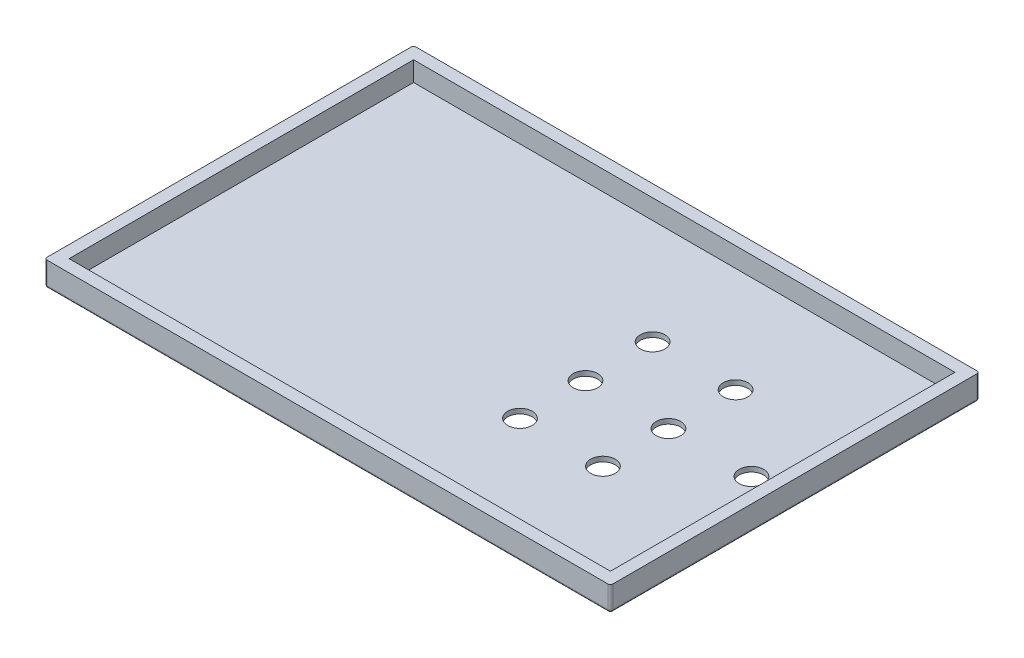
from build123d import *

# Parameters (mm, degrees)
SKETCH1_W           = 230
SKETCH1_H           = 150
BOSS_EXTRUDE3_DEPTH = 10
SKETCH3_W           = 220.032470936
SKETCH3_H           = 140.023771478
CUT_EXTRUDE1_DEPTH  = 8
FILLET1_R           = 1
FILLET2_R           = 1
FILLET3_R           = 1
SKETCH6_R           = 5
CUT_EXTRUDE3_DEPTH  = 10


with BuildPart() as part:
    # Sketch1 → Boss-Extrude3 (new body)
    with BuildSketch(Plane(origin=(0, 0, 0), x_dir=(1, 0, 0), z_dir=(0, 1, 0))):
        with Locations((115, 75)):
            Rectangle(SKETCH1_W, SKETCH1_H)
    extrude(amount=BOSS_EXTRUDE3_DEPTH)

    # Sketch3 → Cut-Extrude1 (cut)
    with BuildSketch(Plane(origin=(0, 10, 0), x_dir=(1, 0, 0), z_dir=(0, 1, 0))):
        with Locations((115, 75)):
            Rectangle(SKETCH3_W, SKETCH3_H)
    extrude(amount=-CUT_EXTRUDE1_DEPTH, mode=Mode.SUBTRACT)

    # Fillet1
    fillet1_edges = [part.edges().sort_by_distance(p)[0] for p in [
        (0, 5, 0),
    ]]
    fillet(fillet1_edges, radius=FILLET1_R)

    # Fillet2
    fillet2_edges = [part.edges().sort_by_distance(p)[0] for p in [
        (0, 5, -150),
        (230, 5, -150),
        (230, 5, 0),
    ]]
    fillet(fillet2_edges, radius=FILLET2_R)

    # Fillet3
    fillet3_edges = [part.edges().sort_by_distance(p)[0] for p in [
        (115, 0, 0),
        (0.292893219, 0, -0.292893219),
        (0, 0, -75),
        (115, 0, -150),
        (230, 0, -75),
        (229.707106781, 0, -149.707106781),
        (229.707106781, 0, -0.292893219),
        (0.292893219, 0, -149.707106781),
    ]]
    fillet(fillet3_edges, radius=FILLET3_R)

    # Sketch6 → Cut-Extrude3 (cut)
    with BuildSketch(Plane.XZ):
        with Locations((144.826508181, -48.408466726)):
            Circle(SKETCH6_R)
        with Locations((178.556568371, -48.408466726)):
            Circle(SKETCH6_R)
        with Locations((178.592552161, -75)):
            Circle(SKETCH6_R)
        with Locations((144.862491971, -75)):
            Circle(SKETCH6_R)
        with Locations((144.862491971, -102.290057641)):
            Circle(SKETCH6_R)
        with Locations((178.592552161, -102.290057641)):
            Circle(SKETCH6_R)
        with Locations((212.322612351, -75)):
            Circle(SKETCH6_R)
    extrude(amount=-CUT_EXTRUDE3_DEPTH, mode=Mode.SUBTRACT)


solid = part.part
